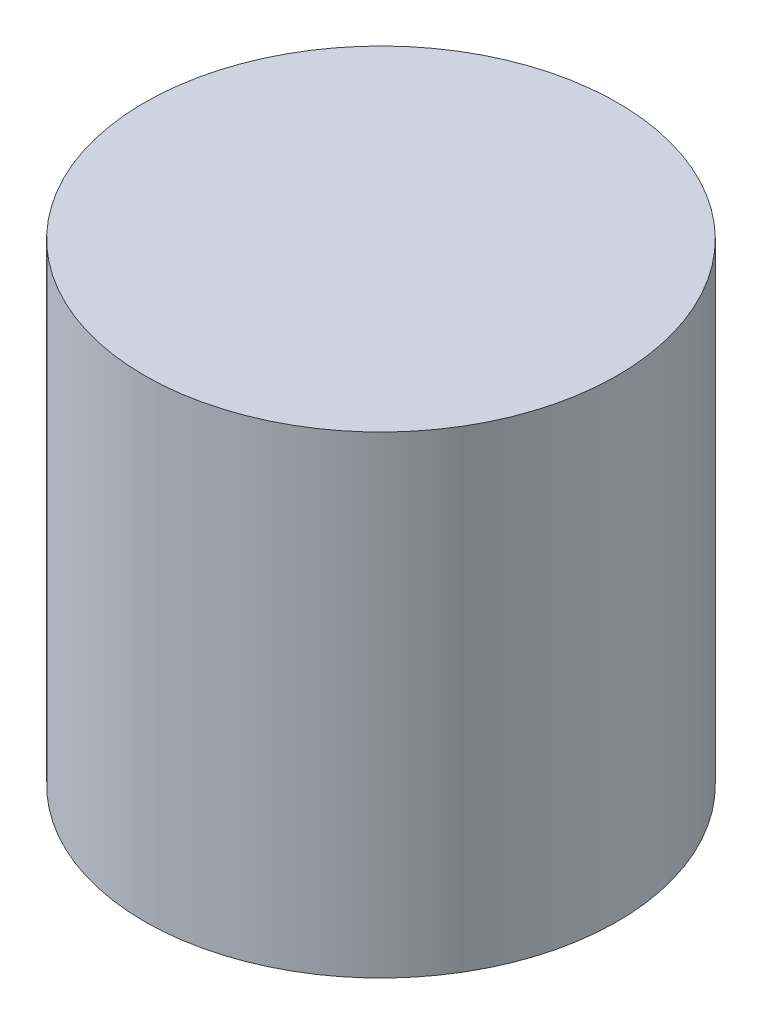
from build123d import *

# Parameters (mm, degrees)
SKETCH1_R           = 63.5
BOSS_EXTRUDE1_DEPTH = 127


with BuildPart() as part:
    # Sketch1 → Boss-Extrude1 (new body)
    with BuildSketch(Plane(origin=(0, 0, 0), x_dir=(1, 0, 0), z_dir=(0, 1, 0))):
        with Locations((-46.101510088, 11.453791326)):
            Circle(SKETCH1_R)
    extrude(amount=BOSS_EXTRUDE1_DEPTH)


solid = part.part
